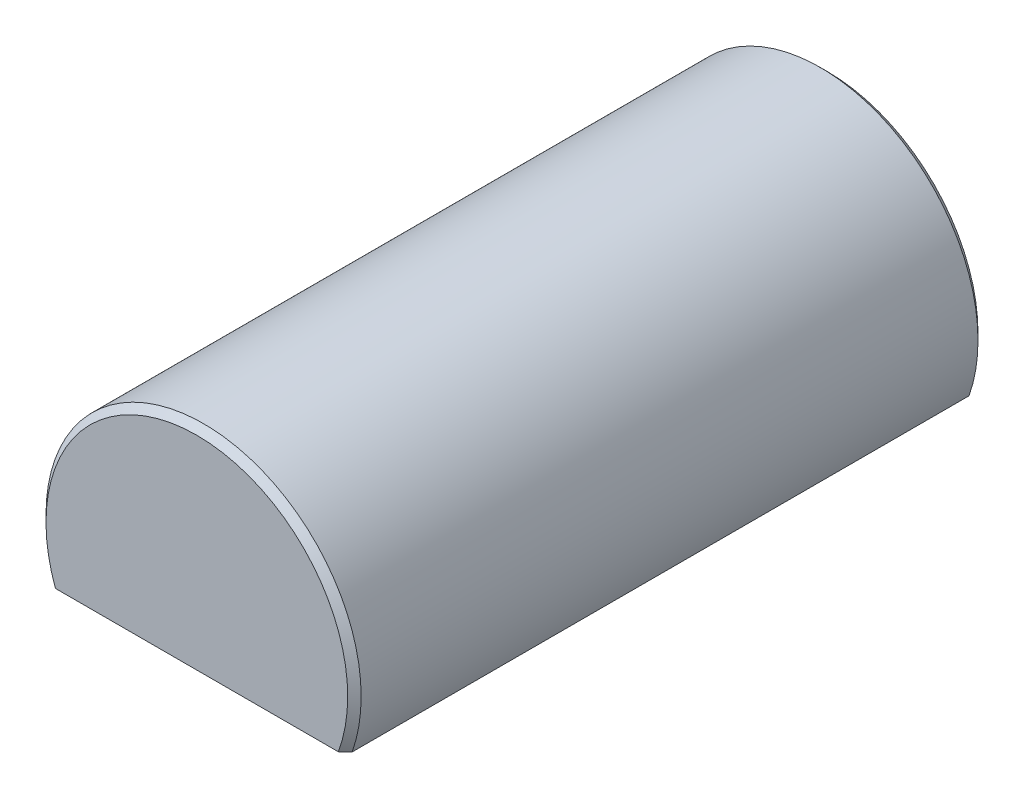
from build123d import *

# Parameters (mm, degrees)
SKETCH1_R            = 9.525
EXTRUDE1_DEPTH       = 19.05
CHAMFER1_SIZE        = 0.4064
TRUNCATED_DEPTH      = 20.05
TRUNCATED_DEPTH_BACK = 20.05
SKETCH6_R            = 2.38125
BLIND_HOLES_DEPTH    = 4.7625


with BuildPart() as part:
    # Sketch1 → Extrude1 (new body, symmetric)
    with BuildSketch(Plane.XY):
        Circle(SKETCH1_R)
    extrude(amount=EXTRUDE1_DEPTH, both=True)

    # Chamfer1
    chamfer1_edges = [part.edges().sort_by_distance(p)[0] for p in [
        (-9.525, 0, -19.05),
        (-9.525, 0, 19.05),
    ]]
    chamfer(chamfer1_edges, length=CHAMFER1_SIZE)

    # Sketch2 → Truncated (cut, two sides)
    with BuildSketch(Plane.XY) as truncated_sk:
        with BuildLine():
            Line((-8.980256121, -3.175), (8.980256121, -3.175))
            ThreePointArc((8.980256121, -3.175), (0, -9.525), (-8.980256121, -3.175))
        make_face()
    extrude(amount=TRUNCATED_DEPTH, mode=Mode.SUBTRACT)
    extrude(truncated_sk.sketch, amount=-TRUNCATED_DEPTH_BACK, mode=Mode.SUBTRACT)

    # Sketch6 → Blind Holes (cut)
    with BuildSketch(Plane(origin=(0, -3.175, 0), x_dir=(-1, 0, 0), z_dir=(0, 1, 0))):
        with Locations(Location((0, 12.7, 0), (0, 0, 90))):  # turned: the seam where the file's is
            Circle(SKETCH6_R)
        with Locations(Location((0, -12.7, 0), (0, 0, 90))):  # turned: the seam where the file's is
            Circle(SKETCH6_R)
    extrude(amount=BLIND_HOLES_DEPTH, mode=Mode.SUBTRACT)


solid = part.part
